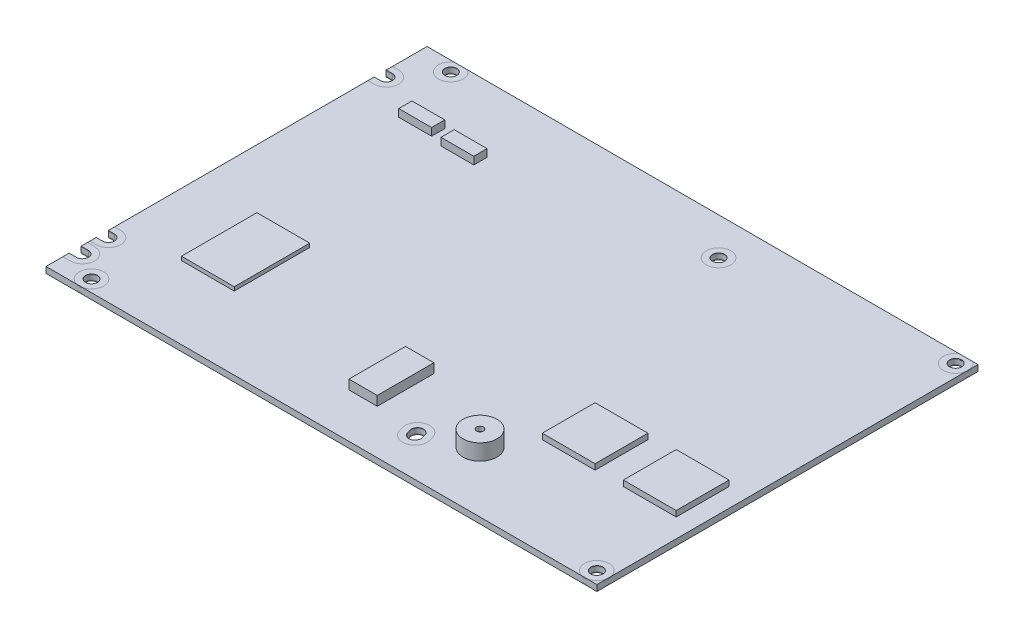
from build123d import *

# Parameters (mm, degrees)
CROQUIS1_R            = 1.6
EXTRUIR1_DEPTH        = 1.6
CROQUIS2_R            = 3.25
CORTAR_EXTRUIR1_DEPTH = 0.2
CROQUIS3_R            = 3.25
CROQUIS3_R_2          = 1.6
EXTRUIR2_DEPTH        = 0.2
EXTRUIR2_2_DEPTH      = 0.2
EXTRUIR2_3_DEPTH      = 0.2
EXTRUIR2_4_DEPTH      = 0.2
EXTRUIR2_5_DEPTH      = 0.2
EXTRUIR2_6_DEPTH      = 0.2
EXTRUIR2_7_DEPTH      = 0.2
EXTRUIR2_8_DEPTH      = 0.2
CROQUIS3_R_3          = 1.606150229
EXTRUIR2_9_DEPTH      = 0.2
CROQUIS4_W            = 14
CROQUIS4_H            = 20
EXTRUIR3_DEPTH        = 1
CROQUIS5_W            = 14
CROQUIS5_H            = 14
EXTRUIR4_DEPTH        = 1.5
EXTRUIR4_2_DEPTH      = 1.5
CROQUIS6_W            = 7.5
CROQUIS6_H            = 15
EXTRUIR5_DEPTH        = 2.5
CROQUIS7_R            = 1
CORTAR_EXTRUIR2_DEPTH = 0.2
CROQUIS8_W            = 8.7
CROQUIS8_H            = 3.5
EXTRUIR6_DEPTH        = 2
EXTRUIR6_2_DEPTH      = 2
CROQUIS9_R            = 4.5
EXTRUIR7_DEPTH        = 4.2
CROQUIS10_R           = 0.915294026
CORTAR_EXTRUIR3_DEPTH = 1.2


with BuildPart() as part:
    # Croquis1 → Extruir1 (new body)
    with BuildSketch(Plane(origin=(0, 0, 0), x_dir=(1, 0, 0), z_dir=(0, 1, 0))):
        with BuildLine():
            Line((0, -14.02), (0, -84.48))
            Line((0, -84.48), (1.64, -84.48))
            ThreePointArc((1.64, -84.48), (3.24, -86.08), (1.64, -87.68))
            Line((1.64, -87.68), (0, -87.68))
            Line((0, -87.68), (0, -91.68))
            Line((0, -91.68), (1.93, -91.68))
            ThreePointArc((1.93, -91.68), (3.53, -93.28), (1.93, -94.88))
            Line((1.93, -94.88), (0, -94.88))
            Line((0, -94.88), (0, -101))
            Line((0, -101), (146.04, -101))
            Line((146.04, -101), (146.04, 0))
            Line((146.04, 0), (0, 0))
            Line((0, 0), (0, -10.82))
            Line((0, -10.82), (1.64, -10.82))
            ThreePointArc((1.64, -10.82), (3.24, -12.42), (1.64, -14.02))
            Line((1.64, -14.02), (0, -14.02))
        make_face()
        with Locations((8.99, -2.7)):
            Circle(CROQUIS1_R, mode=Mode.SUBTRACT)
        with Locations((87.15, -9.88)):
            Circle(CROQUIS1_R, mode=Mode.SUBTRACT)
        with Locations((142.8, -2.68)):
            Circle(CROQUIS1_R, mode=Mode.SUBTRACT)
        with Locations((8.89, -97.82)):
            Circle(CROQUIS1_R, mode=Mode.SUBTRACT)
        with Locations((142.8, -97.8)):
            Circle(CROQUIS1_R, mode=Mode.SUBTRACT)
        with BuildLine():
            Line((88.899048168, -89.45258631), (89.169048168, -90.40258631))
            ThreePointArc((89.169048168, -90.40258631), (88.06741369, -92.379048168), (86.090951832, -91.27741369))
            Line((86.090951832, -91.27741369), (85.820951832, -90.32741369))
            ThreePointArc((85.820951832, -90.32741369), (86.92258631, -88.350951832), (88.899048168, -89.45258631))
        make_face(mode=Mode.SUBTRACT)
    extrude(amount=EXTRUIR1_DEPTH)

    # Croquis2 → Cortar-Extruir1 (cut)
    with BuildSketch(Plane(origin=(0, 1.6, 0), x_dir=(1, 0, 0), z_dir=(0, 1, 0))):
        with Locations((8.99, -2.7)):
            Circle(CROQUIS2_R)
        with Locations((8.89, -97.82)):
            Circle(CROQUIS2_R)
        with Locations((87.15, -9.88)):
            Circle(CROQUIS2_R)
        with Locations((142.8, -2.68)):
            Circle(CROQUIS2_R)
        with Locations((142.8, -97.8)):
            Circle(CROQUIS2_R)
        with BuildLine():
            Line((1.64, -9.17), (-2.325776784, -9.17))
            Line((-2.325776784, -9.17), (-2.325776784, -15.67))
            Line((-2.325776784, -15.67), (1.64, -15.67))
            ThreePointArc((1.64, -15.67), (4.89, -12.42), (1.64, -9.17))
        make_face()
        with BuildLine():
            Line((1.64, -82.83), (-3.18425811, -82.83))
            Line((-3.18425811, -82.83), (-3.18425811, -89.33))
            Line((-3.18425811, -89.33), (1.64, -89.33))
            ThreePointArc((1.64, -89.33), (4.89, -86.08), (1.64, -82.83))
        make_face()
        with BuildLine():
            Line((1.93, -90.03), (-3.18425811, -90.03))
            Line((-3.18425811, -90.03), (-3.18425811, -96.53))
            Line((-3.18425811, -96.53), (1.93, -96.53))
            ThreePointArc((1.93, -96.53), (5.18, -93.28), (1.93, -90.03))
        make_face()
        with BuildLine():
            Line((90.486191592, -89.001503442), (90.756191592, -89.951503442))
            ThreePointArc((90.756191592, -89.951503442), (88.518496558, -93.966191592), (84.503808408, -91.728496558))
            Line((84.503808408, -91.728496558), (84.233808408, -90.778496558))
            ThreePointArc((84.233808408, -90.778496558), (86.471503442, -86.763808408), (90.486191592, -89.001503442))
        make_face()
    cortar_extruir1 = extrude(amount=-CORTAR_EXTRUIR1_DEPTH, mode=Mode.SUBTRACT)

    # Simetría1: Cortar-Extruir1 across plane
    add(cortar_extruir1.mirror(Plane.ZX.offset(0.8)), mode=Mode.SUBTRACT)

    # Croquis7 → Cortar-Extruir2 (cut)
    with BuildSketch(Plane.XZ):
        with Locations((17.46, 62.99)):
            Circle(CROQUIS7_R)
        with Locations((57.62, 62.99)):
            Circle(CROQUIS7_R)
    extrude(amount=-CORTAR_EXTRUIR2_DEPTH, mode=Mode.SUBTRACT)


with BuildPart() as body_2:
    # Croquis3 → Extruir2 (new body)
    with BuildSketch(Plane(origin=(0, 1.4, 0), x_dir=(1, 0, 0), z_dir=(0, 1, 0))):
        with Locations((87.15, -9.88)):
            Circle(CROQUIS3_R)
        with Locations((87.15, -9.88)):
            Circle(CROQUIS3_R_2, mode=Mode.SUBTRACT)
    extrude(amount=EXTRUIR2_DEPTH)


with BuildPart() as body_3:
    # Croquis3 → Extruir2 2 (new body)
    with BuildSketch(Plane(origin=(0, 1.4, 0), x_dir=(1, 0, 0), z_dir=(0, 1, 0))):
        with BuildLine():
            Line((8.219105075, -101), (9.560894925, -101))
            ThreePointArc((9.560894925, -101), (8.89, -94.57), (8.219105075, -101))
        make_face()
        with Locations((8.89, -97.82)):
            Circle(CROQUIS3_R_2, mode=Mode.SUBTRACT)
    extrude(amount=EXTRUIR2_2_DEPTH)


with BuildPart() as body_4:
    # Croquis3 → Extruir2 3 (new body)
    with BuildSketch(Plane(origin=(0, 1.4, 0), x_dir=(1, 0, 0), z_dir=(0, 1, 0))):
        with BuildLine():
            Line((0, -90.03), (0, -91.68))
            Line((0, -91.68), (1.93, -91.68))
            ThreePointArc((1.93, -91.68), (3.53, -93.28), (1.93, -94.88))
            Line((1.93, -94.88), (0, -94.88))
            Line((0, -94.88), (0, -96.53))
            Line((0, -96.53), (1.93, -96.53))
            ThreePointArc((1.93, -96.53), (5.18, -93.28), (1.93, -90.03))
            Line((1.93, -90.03), (0, -90.03))
        make_face()
    extrude(amount=EXTRUIR2_3_DEPTH)


with BuildPart() as body_5:
    # Croquis3 → Extruir2 4 (new body)
    with BuildSketch(Plane(origin=(0, 1.4, 0), x_dir=(1, 0, 0), z_dir=(0, 1, 0))):
        with BuildLine():
            Line((84.233808408, -90.778496558), (84.503808408, -91.728496558))
            ThreePointArc((84.503808408, -91.728496558), (88.518496558, -93.966191592), (90.756191592, -89.951503442))
            Line((90.756191592, -89.951503442), (90.486191592, -89.001503442))
            ThreePointArc((90.486191592, -89.001503442), (86.471503442, -86.763808408), (84.233808408, -90.778496558))
        make_face()
        with BuildLine():
            Line((85.820951832, -90.32741369), (86.090951832, -91.27741369))
            ThreePointArc((86.090951832, -91.27741369), (88.06741369, -92.379048168), (89.169048168, -90.40258631))
            Line((89.169048168, -90.40258631), (88.899048168, -89.45258631))
            ThreePointArc((88.899048168, -89.45258631), (86.92258631, -88.350951832), (85.820951832, -90.32741369))
        make_face(mode=Mode.SUBTRACT)
    extrude(amount=EXTRUIR2_4_DEPTH)


with BuildPart() as body_6:
    # Croquis3 → Extruir2 5 (new body)
    with BuildSketch(Plane(origin=(0, 1.4, 0), x_dir=(1, 0, 0), z_dir=(0, 1, 0))):
        with BuildLine():
            Line((0, -82.83), (0, -84.48))
            Line((0, -84.48), (1.64, -84.48))
            ThreePointArc((1.64, -84.48), (3.24, -86.08), (1.64, -87.68))
            Line((1.64, -87.68), (0, -87.68))
            Line((0, -87.68), (0, -89.33))
            Line((0, -89.33), (1.64, -89.33))
            ThreePointArc((1.64, -89.33), (4.89, -86.08), (1.64, -82.83))
            Line((1.64, -82.83), (0, -82.83))
        make_face()
    extrude(amount=EXTRUIR2_5_DEPTH)


with BuildPart() as body_7:
    # Croquis3 → Extruir2 6 (new body)
    with BuildSketch(Plane(origin=(0, 1.4, 0), x_dir=(1, 0, 0), z_dir=(0, 1, 0))):
        with BuildLine():
            Line((142.232109165, -101), (143.367890835, -101))
            ThreePointArc((143.367890835, -101), (145.206995118, -99.983775287), (146.04, -98.054754784))
            Line((146.04, -98.054754784), (146.04, -97.545245216))
            ThreePointArc((146.04, -97.545245216), (140.616224713, -95.393004882), (142.232109165, -101))
        make_face()
        with Locations((142.8, -97.8)):
            Circle(CROQUIS3_R_2, mode=Mode.SUBTRACT)
    extrude(amount=EXTRUIR2_6_DEPTH)


with BuildPart() as body_8:
    # Croquis3 → Extruir2 7 (new body)
    with BuildSketch(Plane(origin=(0, 1.4, 0), x_dir=(1, 0, 0), z_dir=(0, 1, 0))):
        with BuildLine():
            Line((10.799005252, 0), (7.180994748, 0))
            ThreePointArc((7.180994748, 0), (8.99, -5.95), (10.799005252, 0))
        make_face()
        with Locations((8.99, -2.7)):
            Circle(CROQUIS3_R_2, mode=Mode.SUBTRACT)
    extrude(amount=EXTRUIR2_7_DEPTH)


with BuildPart() as body_9:
    # Croquis3 → Extruir2 8 (new body)
    with BuildSketch(Plane(origin=(0, 1.4, 0), x_dir=(1, 0, 0), z_dir=(0, 1, 0))):
        with BuildLine():
            Line((0, -9.17), (0, -10.82))
            Line((0, -10.82), (1.64, -10.82))
            ThreePointArc((1.64, -10.82), (3.24, -12.42), (1.64, -14.02))
            Line((1.64, -14.02), (0, -14.02))
            Line((0, -14.02), (0, -15.67))
            Line((0, -15.67), (1.64, -15.67))
            ThreePointArc((1.64, -15.67), (4.89, -12.42), (1.64, -9.17))
            Line((1.64, -9.17), (0, -9.17))
        make_face()
    extrude(amount=EXTRUIR2_8_DEPTH)


with BuildPart() as body_10:
    # Croquis3 → Extruir2 9 (new body)
    with BuildSketch(Plane(origin=(0, 1.4, 0), x_dir=(1, 0, 0), z_dir=(0, 1, 0))):
        with BuildLine():
            Line((146.04, -2.934754784), (146.04, -2.425245216))
            ThreePointArc((146.04, -2.425245216), (145.61393966, -1.053886969), (144.638504827, 0))
            Line((144.638504827, 0), (140.961495173, 0))
            ThreePointArc((140.961495173, 0), (141.173886969, -5.49393966), (146.04, -2.934754784))
        make_face()
        with Locations((142.8, -2.68)):
            Circle(CROQUIS3_R_3, mode=Mode.SUBTRACT)
    extrude(amount=EXTRUIR2_9_DEPTH)


with BuildPart() as body_11:
    # Simetría2: mirrored copy
    add(body_4.part.mirror(Plane.ZX.offset(0.8)))


with BuildPart() as body_12:
    # Simetr_a2 2: mirrored copy
    add(body_6.part.mirror(Plane.ZX.offset(0.8)))


with BuildPart() as body_13:
    # Simetr_a2 3: mirrored copy
    add(body_3.part.mirror(Plane.ZX.offset(0.8)))


with BuildPart() as body_14:
    # Simetr_a2 4: mirrored copy
    add(body_8.part.mirror(Plane.ZX.offset(0.8)))


with BuildPart() as body_15:
    # Simetr_a2 5: mirrored copy
    add(body_9.part.mirror(Plane.ZX.offset(0.8)))


with BuildPart() as body_16:
    # Simetr_a2 6: mirrored copy
    add(body_7.part.mirror(Plane.ZX.offset(0.8)))


with BuildPart() as body_17:
    # Simetr_a2 7: mirrored copy
    add(body_5.part.mirror(Plane.ZX.offset(0.8)))


with BuildPart() as body_18:
    # Simetr_a2 8: mirrored copy
    add(body_2.part.mirror(Plane.ZX.offset(0.8)))


with BuildPart() as body_19:
    # Simetr_a2 9: mirrored copy
    add(body_10.part.mirror(Plane.ZX.offset(0.8)))


with BuildPart() as body_20:
    # Croquis4 → Extruir3 (new body)
    with BuildSketch(Plane(origin=(0, 1.6, 0), x_dir=(1, 0, 0), z_dir=(0, 1, 0))):
        with Locations((23.6, -71.7)):
            Rectangle(CROQUIS4_W, CROQUIS4_H)
    extrude(amount=EXTRUIR3_DEPTH)


with BuildPart() as body_21:
    # Croquis5 → Extruir4 (new body)
    with BuildSketch(Plane(origin=(0, 1.6, 0), x_dir=(1, 0, 0), z_dir=(0, 1, 0))):
        with Locations((112.54, -68)):
            Rectangle(CROQUIS5_W, CROQUIS5_H)
    extrude(amount=EXTRUIR4_DEPTH)


with BuildPart() as body_22:
    # Croquis5 → Extruir4 2 (new body)
    with BuildSketch(Plane(origin=(0, 1.6, 0), x_dir=(1, 0, 0), z_dir=(0, 1, 0))):
        with Locations((134.04, -68)):
            Rectangle(CROQUIS5_W, CROQUIS5_H)
    extrude(amount=EXTRUIR4_2_DEPTH)


with BuildPart() as body_23:
    # Croquis6 → Extruir5 (new body)
    with BuildSketch(Plane(origin=(0, 1.6, 0), x_dir=(1, 0, 0), z_dir=(0, 1, 0))):
        with Locations((72.25, -81.7)):
            Rectangle(CROQUIS6_W, CROQUIS6_H)
    extrude(amount=EXTRUIR5_DEPTH)


with BuildPart() as body_24:
    # Croquis8 → Extruir6 (new body)
    with BuildSketch(Plane(origin=(0, 1.6, 0), x_dir=(1, 0, 0), z_dir=(0, 1, 0))):
        with Locations((29.05, -19.25)):
            Rectangle(CROQUIS8_W, CROQUIS8_H)
    extrude(amount=EXTRUIR6_DEPTH)


with BuildPart() as body_25:
    # Croquis8 → Extruir6 2 (new body)
    with BuildSketch(Plane(origin=(0, 1.6, 0), x_dir=(1, 0, 0), z_dir=(0, 1, 0))):
        with Locations((16.85, -18.25)):
            Rectangle(CROQUIS8_W, CROQUIS8_H)
    extrude(amount=EXTRUIR6_2_DEPTH)


with BuildPart() as body_26:
    # Croquis9 → Extruir7 (new body)
    with BuildSketch(Plane(origin=(0, 1.6, 0), x_dir=(1, 0, 0), z_dir=(0, 1, 0))):
        with Locations((99.04, -85)):
            Circle(CROQUIS9_R)
    extrude(amount=EXTRUIR7_DEPTH)

    # Croquis10 → Cortar-Extruir3 (cut)
    with BuildSketch(Plane(origin=(0, 5.8, 0), x_dir=(1, 0, 0), z_dir=(0, 1, 0))):
        with Locations((99.04, -85)):
            Circle(CROQUIS10_R)
    extrude(amount=-CORTAR_EXTRUIR3_DEPTH, mode=Mode.SUBTRACT)


solid = Compound([part.part, body_2.part, body_3.part, body_4.part, body_5.part, body_6.part, body_7.part, body_8.part, body_9.part, body_10.part, body_11.part, body_12.part, body_13.part, body_14.part, body_15.part, body_16.part, body_17.part, body_18.part, body_19.part, body_20.part, body_21.part, body_22.part, body_23.part, body_24.part, body_25.part, body_26.part])
